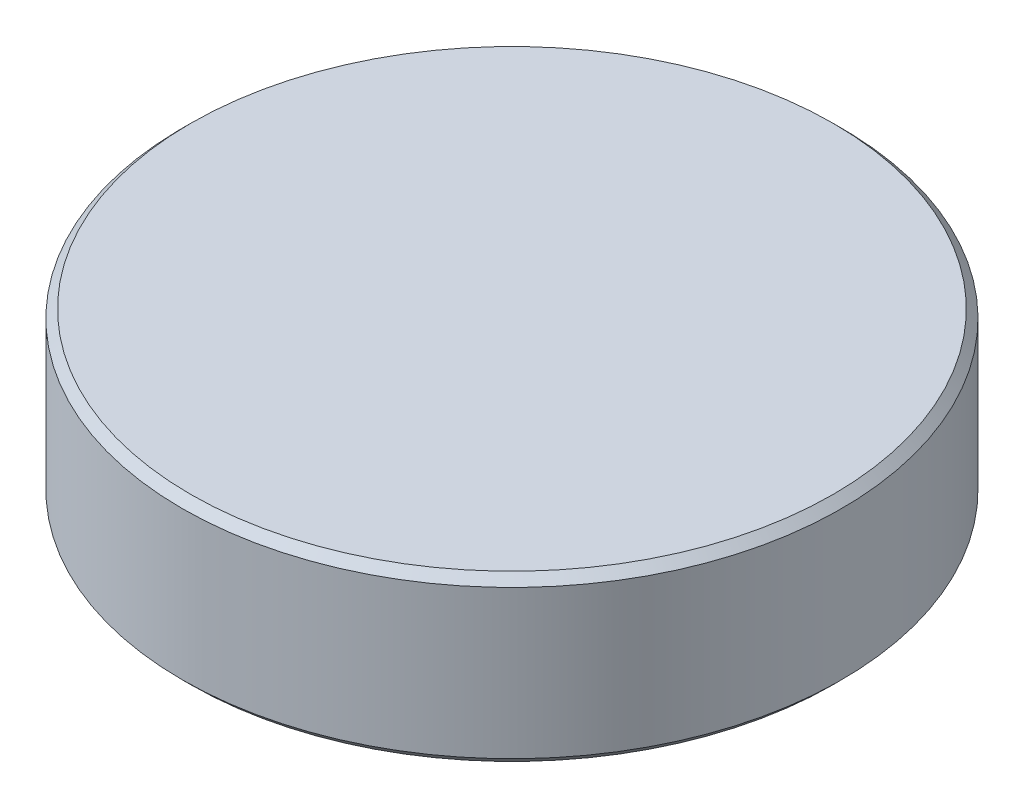
from build123d import *

# Parameters (mm, degrees)
ESQUISSE1_R      = 100
EXTRUSION1_DEPTH = 50
CHANFREIN1_SIZE  = 2.5


with BuildPart() as part:
    # Esquisse1 → Extrusion1 (new body)
    with BuildSketch(Plane(origin=(0, 0, 0), x_dir=(1, 0, 0), z_dir=(0, 1, 0))):
        Circle(ESQUISSE1_R)
    extrude(amount=EXTRUSION1_DEPTH)

    # Chanfrein1
    chanfrein1_edges = [part.edges().sort_by_distance(p)[0] for p in [
        (-100, 0, 0),
        (-100, 50, 0),
    ]]
    chamfer(chanfrein1_edges, length=CHANFREIN1_SIZE)


solid = part.part
